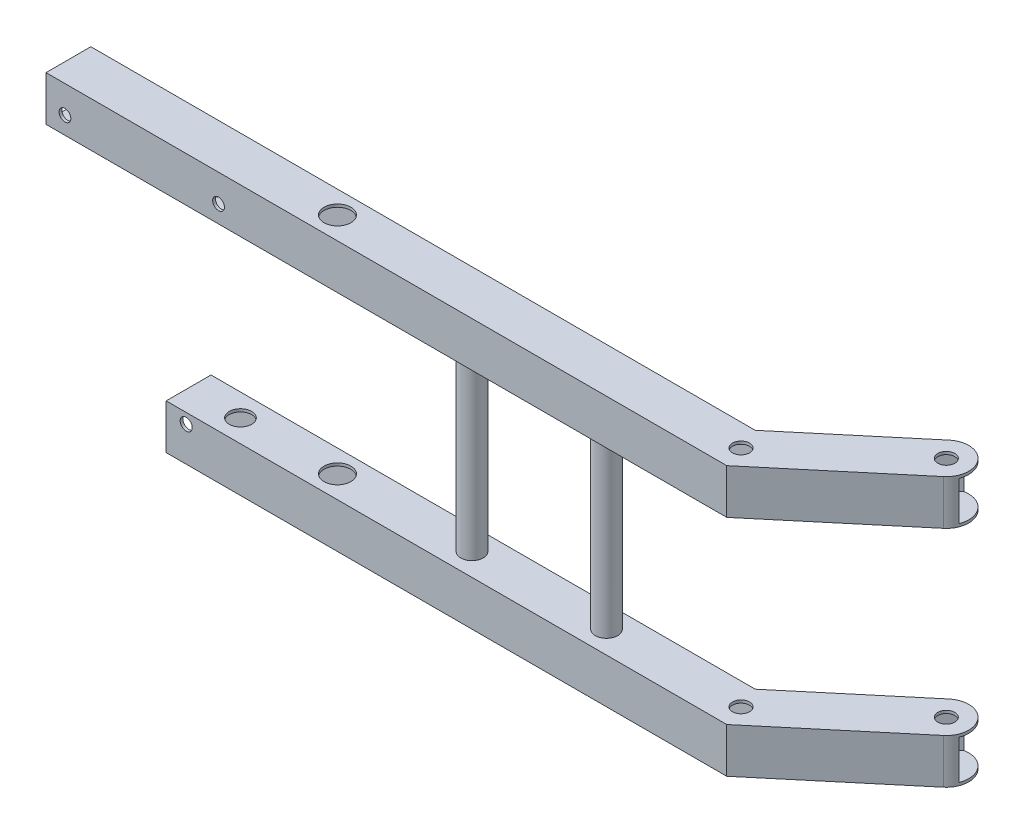
from build123d import *

# Parameters (mm, degrees)
SKETCH4_R           = 4.826
SKETCH4_R_2         = 7.62
BOSS_EXTRUDE3_DEPTH = 152.4
SKETCH5_W           = 22.225
SKETCH5_H           = 22.225
SKETCH5_W_2         = 25.4
SKETCH5_H_2         = 101.6
CUT_EXTRUDE2_DEPTH  = 258.622422
SKETCH6_W           = 25.4
SKETCH6_H           = 101.6
SKETCH6_W_2         = 22.225
SKETCH6_H_2         = 22.225
CUT_EXTRUDE3_DEPTH  = 123.590867
CUT_EXTRUDE4_DEPTH  = 152.4
SKETCH8_R           = 6.35
BOSS_EXTRUDE4_DEPTH = 101.6
SKETCH9_W           = 25.4
SKETCH9_H           = 25.4
SKETCH9_W_2         = 22.225
SKETCH9_H_2         = 22.225
BOSS_EXTRUDE5_DEPTH = 58.928
SKETCH11_R          = 1.65
CUT_EXTRUDE6_DEPTH  = 1.5875
SKETCH12_R          = 6.35
CUT_EXTRUDE7_DEPTH  = 103.1875
SKETCH13_W          = 25.4
SKETCH13_H          = 25.4
SKETCH13_W_2        = 22.225
SKETCH13_H_2        = 22.225
BOSS_EXTRUDE6_DEPTH = 68.072
SKETCH14_R          = 3.33
SKETCH14_R_2        = 3.42
CUT_EXTRUDE8_DEPTH  = 1.5875


with BuildPart() as part:
    # Sketch4 → Boss-Extrude3 (new body)
    with BuildSketch(Plane(origin=(0, 0, 0), x_dir=(1, 0, 0), z_dir=(0, 1, 0))):
        Polygon((-254, -12.7), (-254, 12.7), (-4.622421975, 12.7), (82.971713376, 86.200206667), (99.298518662, 66.742677811), (4.622421975, -12.7), align=None)
        Circle(SKETCH4_R, mode=Mode.SUBTRACT)
        with Locations((63.236968779, 53.06211718)):
            Circle(SKETCH4_R, mode=Mode.SUBTRACT)
        with Locations((-228.6, 0)):
            Circle(SKETCH4_R_2, mode=Mode.SUBTRACT)
    extrude(amount=BOSS_EXTRUDE3_DEPTH)

    # Sketch5 → Cut-Extrude2 (cut)
    with BuildSketch(Plane.ZY.offset(254)):
        with Locations((0, 139.7)):
            Rectangle(SKETCH5_W, SKETCH5_H)
        with Locations((0, 76.2)):
            Rectangle(SKETCH5_W_2, SKETCH5_H_2)
        with Locations((0, 12.7)):
            Rectangle(SKETCH5_W, SKETCH5_H)
    extrude(amount=-CUT_EXTRUDE2_DEPTH, mode=Mode.SUBTRACT)

    # Sketch6 → Cut-Extrude3 (cut)
    with BuildSketch(Plane(origin=(91.135116019, 0, -76.471442239), x_dir=(-0.64278761, 0, -0.766044443), z_dir=(0.766044443, 0, -0.64278761))):
        with Locations((0, 76.2)):
            Rectangle(SKETCH6_W, SKETCH6_H)
        with Locations((0, 139.7)):
            Rectangle(SKETCH6_W_2, SKETCH6_H_2)
        with Locations((0, 12.7)):
            Rectangle(SKETCH6_W_2, SKETCH6_H_2)
    extrude(amount=-CUT_EXTRUDE3_DEPTH, mode=Mode.SUBTRACT)

    # Sketch7 → Cut-Extrude4 (cut)
    with BuildSketch(Plane(origin=(0, 152.4, 0), x_dir=(1, 0, 0), z_dir=(0, 1, 0))):
        with BuildLine():
            Line((55.073566136, 62.790881607), (14.292485888, 190.379547218))
            Line((14.292485888, 190.379547218), (153.844328146, 116.591677596))
            Line((153.844328146, 116.591677596), (141.535463421, -3.473116834))
            Line((141.535463421, -3.473116834), (71.400371422, 43.333352752))
            ThreePointArc((71.400371422, 43.333352752), (72.965733207, 61.225519823), (55.073566136, 62.790881607))
        make_face()
    extrude(amount=-CUT_EXTRUDE4_DEPTH, mode=Mode.SUBTRACT)

    # Sketch8 → Boss-Extrude4 (add)
    with BuildSketch(Plane.XZ.offset(-127)):
        with Locations((-76.2, 0)):
            Circle(SKETCH8_R)
        with Locations((-152.4, 0)):
            Circle(SKETCH8_R)
    extrude(amount=BOSS_EXTRUDE4_DEPTH)

    # Sketch9 → Boss-Extrude5 (add)
    with BuildSketch(Plane.ZY.offset(254)):
        with Locations((0, 139.7)):
            Rectangle(SKETCH9_W, SKETCH9_H)
        with Locations((0, 139.7)):
            Rectangle(SKETCH9_W_2, SKETCH9_H_2, mode=Mode.SUBTRACT)
        with Locations((0, 12.7)):
            Rectangle(SKETCH9_W, SKETCH9_H)
        with Locations((0, 12.7)):
            Rectangle(SKETCH9_W_2, SKETCH9_H_2, mode=Mode.SUBTRACT)
    extrude(amount=BOSS_EXTRUDE5_DEPTH)

    # Sketch11 → Cut-Extrude6 (cut)
    with BuildSketch(Plane.XZ.offset(-127)):
        with Locations((-271.054789466, 0)):
            Circle(SKETCH11_R)
        with Locations((-296.054789466, 0)):
            Circle(SKETCH11_R)
    extrude(amount=-CUT_EXTRUDE6_DEPTH, mode=Mode.SUBTRACT)

    # Sketch12 → Cut-Extrude7 (cut)
    with BuildSketch(Plane.XZ.offset(-127)):
        with Locations((-283.554789466, 0)):
            Circle(SKETCH12_R)
    extrude(amount=CUT_EXTRUDE7_DEPTH, mode=Mode.SUBTRACT)

    # Sketch13 → Boss-Extrude6 (add)
    with BuildSketch(Plane.ZY.offset(312.928)):
        with Locations((0, 139.7)):
            Rectangle(SKETCH13_W, SKETCH13_H)
        with Locations((0, 139.7)):
            Rectangle(SKETCH13_W_2, SKETCH13_H_2, mode=Mode.SUBTRACT)
    extrude(amount=BOSS_EXTRUDE6_DEPTH)

    # Sketch14 → Cut-Extrude8 (cut)
    with BuildSketch(Plane.XY.offset(12.7)):
        with Locations((-370.26, 136.87)):
            Circle(SKETCH14_R)
        with Locations((-283.26, 136.87)):
            Circle(SKETCH14_R)
        with Locations((-301.58, 19.63)):
            Circle(SKETCH14_R_2)
    extrude(amount=-CUT_EXTRUDE8_DEPTH, mode=Mode.SUBTRACT)


solid = part.part
